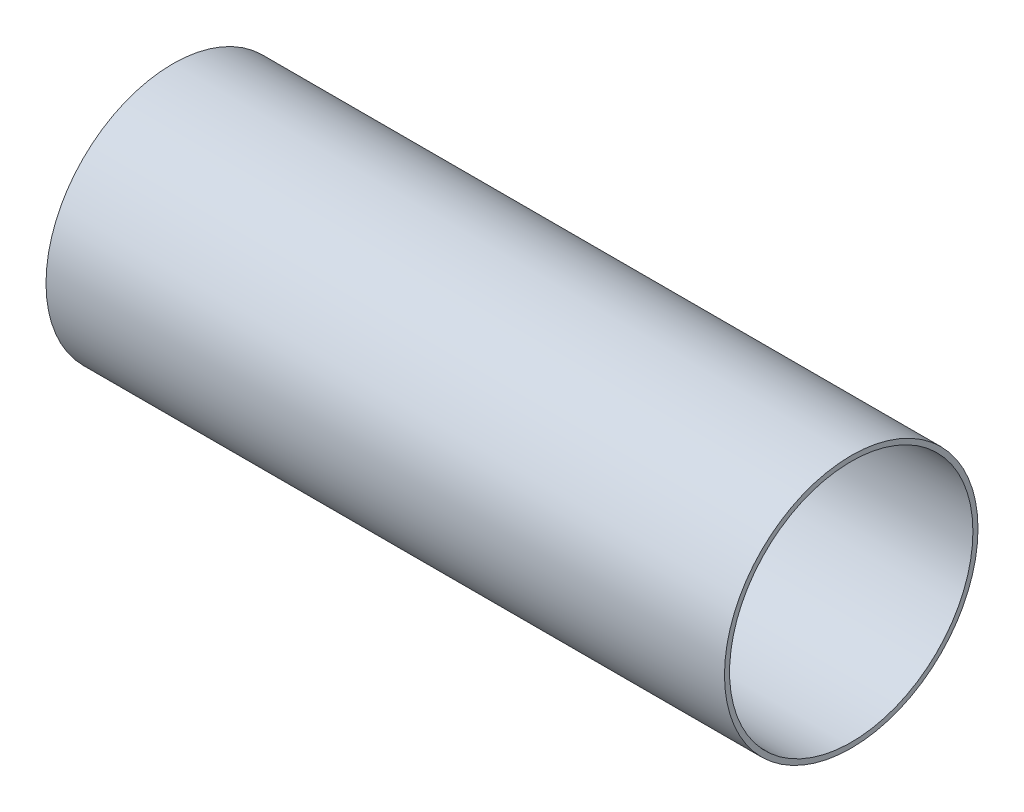
from build123d import *

# Parameters (mm, degrees)
SKETCH1_R           = 28.4734
SKETCH1_R_2         = 27.3304
BOSS_EXTRUDE1_DEPTH = 152.4


with BuildPart() as part:
    # Sketch1 → Boss-Extrude1 (new body)
    with BuildSketch(Plane(origin=(0, 0, 0), x_dir=(0, 0, -1), z_dir=(1, 0, 0))):
        Circle(SKETCH1_R)
        Circle(SKETCH1_R_2, mode=Mode.SUBTRACT)
    extrude(amount=BOSS_EXTRUDE1_DEPTH)


solid = part.part
